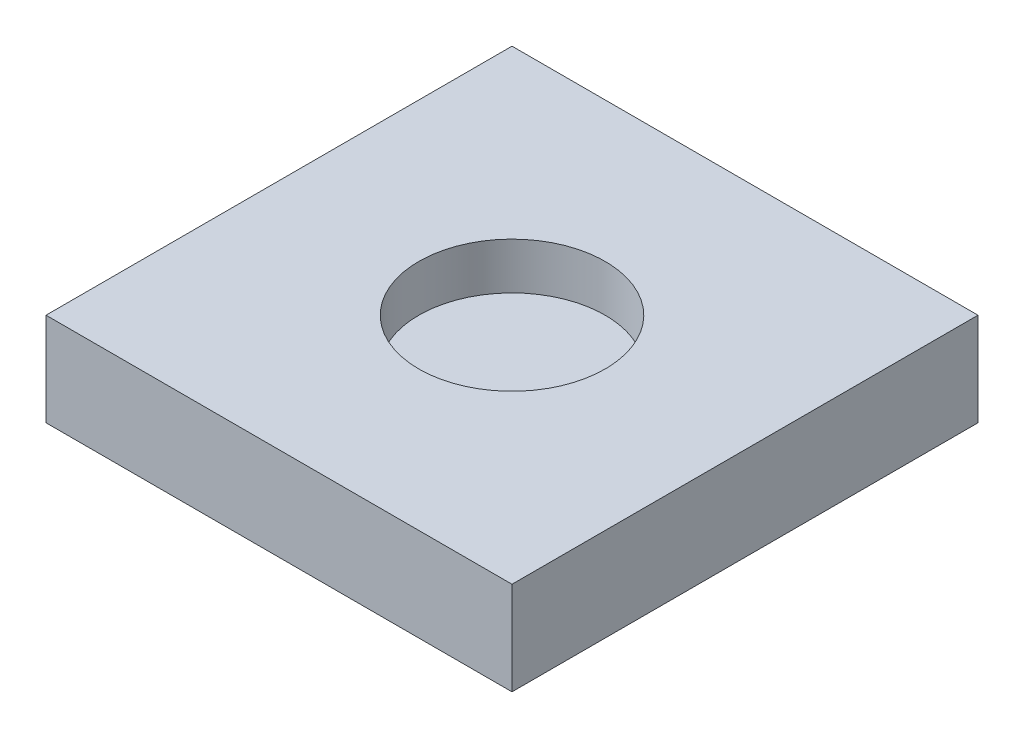
from build123d import *

# Parameters (mm, degrees)
SKETCH_1_W          = 500
SKETCH_1_H          = 100
EXTRUDE_1_DEPTH     = 250
SKETCH_2_R          = 100
CUT_EXTRUDE_1_DEPTH = 50


with BuildPart() as part:
    # 草图1 → 凸台-拉伸1 (new body, symmetric)
    with BuildSketch(Plane.XY):
        Rectangle(SKETCH_1_W, SKETCH_1_H)
    extrude(amount=EXTRUDE_1_DEPTH, both=True)

    # 草图2 → 切除-拉伸1 (cut)
    with BuildSketch(Plane(origin=(0, 50, 0), x_dir=(1, 0, 0), z_dir=(0, 1, 0))):
        Circle(SKETCH_2_R)
    extrude(amount=-CUT_EXTRUDE_1_DEPTH, mode=Mode.SUBTRACT)


solid = part.part
